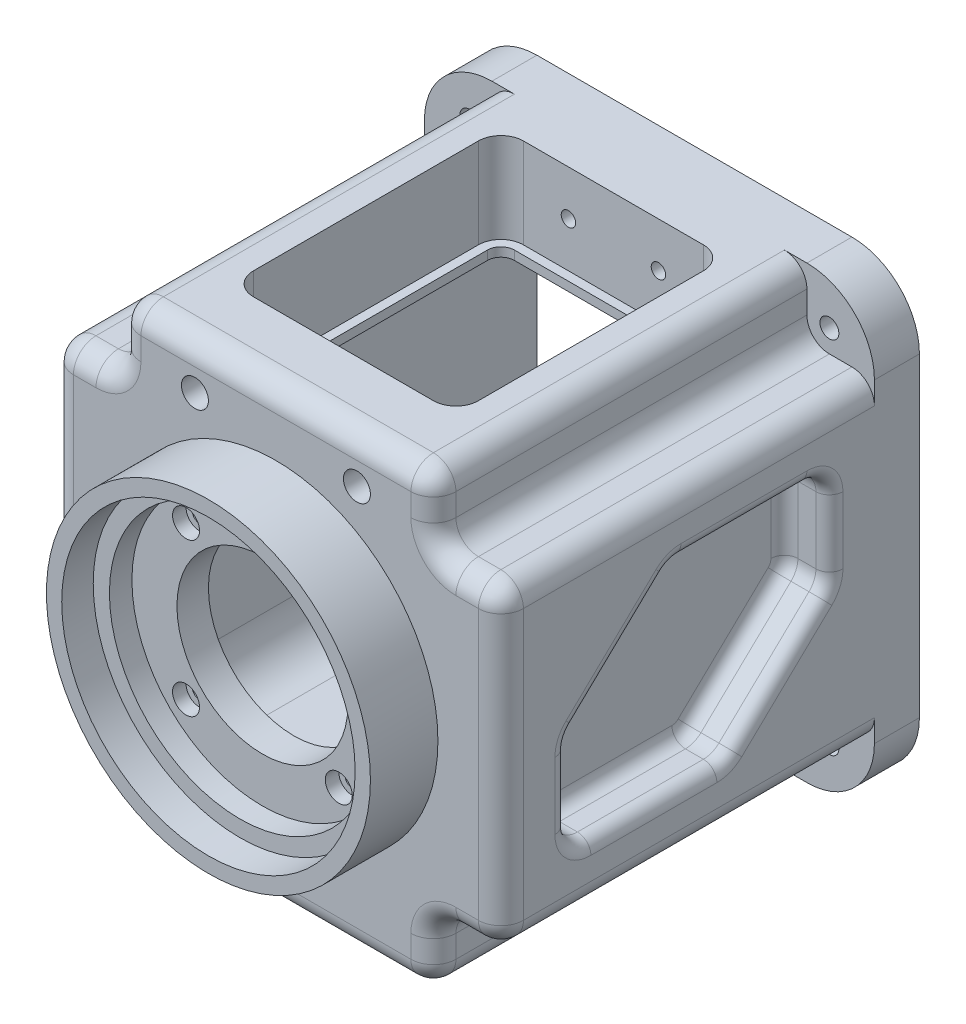
from build123d import *

# Parameters (mm, degrees)
SKETCH_1_W           = 100
SKETCH_1_H           = 100
EXTRUDE_1_DEPTH      = 93
FILLET_1_R           = 15
CUT_EXTRUDE_1_DEPTH  = 83
SKETCH_3_R           = 25
SKETCH_3_R_2         = 15
CUT_EXTRUDE_2_DEPTH  = 7
SKETCH_4_R           = 24
SKETCH_4_R_2         = 16
CUT_EXTRUDE_3_DEPTH  = 3
CHAMFER_1_SIZE       = 1
SKETCH_5_R           = 36
EXTRUDE_2_DEPTH      = 15
SKETCH_6_R           = 32.6
CUT_EXTRUDE_4_DEPTH  = 7
SKETCH_7_R           = 29
CUT_EXTRUDE_5_DEPTH  = 5
SKETCH_8_R           = 19
SKETCH_8_R_2         = 1.6
CUT_EXTRUDE_6_DEPTH  = 97
SKETCH_9_R           = 3
CUT_EXTRUDE_7_DEPTH  = 3
CUT_EXTRUDE_8_DEPTH  = 88
SKETCH_12_W          = 42.2
SKETCH_12_H          = 42.2
CUT_EXTRUDE_9_DEPTH  = 1
FILLET_3_R           = 5
CUT_EXTRUDE_10_REACH = 102
CUT_EXTRUDE_11_DEPTH = 20
CUT_EXTRUDE_12_DEPTH = 10
FILLET_4_R           = 5
FILLET_5_R           = 3
SKETCH_16_R          = 2.1
CUT_EXTRUDE_13_DEPTH = 109
CUT_EXTRUDE_14_REACH = 92
CUT_EXTRUDE_15_REACH = 110
SKETCH_18_R          = 1.6
SKETCH_19_R          = 3
CUT_EXTRUDE_16_DEPTH = 10
SKETCH_20_R          = 1.6
CUT_EXTRUDE_17_DEPTH = 31
SKETCH_21_R          = 3
CUT_EXTRUDE_18_DEPTH = 8


with BuildPart() as part:
    # 草图1 → 凸台-拉伸1 (new body)
    with BuildSketch(Plane.XY):
        Rectangle(SKETCH_1_W, SKETCH_1_H)
    extrude(amount=EXTRUDE_1_DEPTH)

    # 圆角1
    fillet_1_edges = [part.edges().sort_by_distance(p)[0] for p in [
        (50, -50, 46.5),
        (-50, -50, 46.5),
        (-50, 50, 46.5),
        (50, 50, 46.5),
    ]]
    fillet(fillet_1_edges, radius=FILLET_1_R)

    # 草图2 → 切除-拉伸1 (cut)
    with BuildSketch(Plane.XY.offset(93)):
        with BuildLine():
            Line((-35, 50), (-50, 50))
            Line((-50, 50), (-50, 35))
            Line((-50, 35), (-40, 35))
            ThreePointArc((-40, 35), (-36.464466094, 36.464466094), (-35, 40))
            Line((-35, 40), (-35, 50))
        make_face()
        with BuildLine():
            Line((50, 35), (40, 35))
            ThreePointArc((40, 35), (36.464466094, 36.464466094), (35, 40))
            Line((35, 40), (35, 50))
            Line((35, 50), (50, 50))
            Line((50, 50), (50, 35))
        make_face()
        with BuildLine():
            Line((35, -50), (35, -40))
            ThreePointArc((35, -40), (36.464466094, -36.464466094), (40, -35))
            Line((40, -35), (50, -35))
            Line((50, -35), (50, -50))
            Line((50, -50), (35, -50))
        make_face()
        with BuildLine():
            Line((-50, -35), (-40, -35))
            ThreePointArc((-40, -35), (-36.464466094, -36.464466094), (-35, -40))
            Line((-35, -40), (-35, -50))
            Line((-35, -50), (-50, -50))
            Line((-50, -50), (-50, -35))
        make_face()
    extrude(amount=-CUT_EXTRUDE_1_DEPTH, mode=Mode.SUBTRACT)

    # 草图3 → 切除-拉伸2 (cut)
    with BuildSketch(Plane.XZ.offset(50)):
        with Locations((0, 46.5)):
            Circle(SKETCH_3_R)
        with Locations((0, 46.5)):
            Circle(SKETCH_3_R_2, mode=Mode.SUBTRACT)
    extrude(amount=-CUT_EXTRUDE_2_DEPTH, mode=Mode.SUBTRACT)

    # 草图4 → 切除-拉伸3 (cut)
    with BuildSketch(Plane.XZ.offset(43)):
        with Locations((0, 46.5)):
            Circle(SKETCH_4_R)
        with Locations((0, 46.5)):
            Circle(SKETCH_4_R_2, mode=Mode.SUBTRACT)
    extrude(amount=-CUT_EXTRUDE_3_DEPTH, mode=Mode.SUBTRACT)

    # 倒角1
    chamfer_1_edges = [part.edges().sort_by_distance(p)[0] for p in [
        (-25, -50, 46.5),
        (-15, -50, 46.5),
    ]]
    chamfer(chamfer_1_edges, length=CHAMFER_1_SIZE)

    # 草图5 → 凸台-拉伸2 (add)
    with BuildSketch(Plane.XY.offset(93)):
        Circle(SKETCH_5_R)
    extrude(amount=EXTRUDE_2_DEPTH)

    # 草图6 → 切除-拉伸4 (cut)
    with BuildSketch(Plane.XY.offset(108)):
        Circle(SKETCH_6_R)
    extrude(amount=-CUT_EXTRUDE_4_DEPTH, mode=Mode.SUBTRACT)

    # 草图7 → 切除-拉伸5 (cut)
    with BuildSketch(Plane.XY.offset(101)):
        Circle(SKETCH_7_R)
    extrude(amount=-CUT_EXTRUDE_5_DEPTH, mode=Mode.SUBTRACT)

    # 草图8 → 切除-拉伸6 (cut, through all)
    with BuildSketch(Plane.XY.offset(96)):
        Circle(SKETCH_8_R)
        with Locations((-16.970562748, 16.970562748)):
            Circle(SKETCH_8_R_2)
        with Locations((16.970562748, 16.970562748)):
            Circle(SKETCH_8_R_2)
        with Locations((16.970562748, -16.970562748)):
            Circle(SKETCH_8_R_2)
        with Locations((-16.970562748, -16.970562748)):
            Circle(SKETCH_8_R_2)
    extrude(amount=-CUT_EXTRUDE_6_DEPTH, mode=Mode.SUBTRACT)

    # 草图9 → 切除-拉伸7 (cut)
    with BuildSketch(Plane.XY.offset(96)):
        with Locations((-16.970562748, 16.970562748)):
            Circle(SKETCH_9_R)
        with Locations((16.970562748, 16.970562748)):
            Circle(SKETCH_9_R)
        with Locations((-16.970562748, -16.970562748)):
            Circle(SKETCH_9_R)
        with Locations((16.970562748, -16.970562748)):
            Circle(SKETCH_9_R)
    extrude(amount=-CUT_EXTRUDE_7_DEPTH, mode=Mode.SUBTRACT)

    # 草图11 → 切除-拉伸8 (cut)
    with BuildSketch(Plane(origin=(0, 0, 0), x_dir=(-1, 0, 0), z_dir=(0, 0, -1))):
        with BuildLine():
            Line((-25, 28), (25, 28))
            ThreePointArc((25, 28), (32.071067812, 25.071067812), (35, 18))
            Line((35, 18), (35, -27))
            ThreePointArc((35, -27), (32.071067812, -34.071067812), (25, -37))
            Line((25, -37), (-25, -37))
            ThreePointArc((-25, -37), (-32.071067812, -34.071067812), (-35, -27))
            Line((-35, -27), (-35, 18))
            ThreePointArc((-35, 18), (-32.071067812, 25.071067812), (-25, 28))
        make_face()
    extrude(amount=-CUT_EXTRUDE_8_DEPTH, mode=Mode.SUBTRACT)

    # 草图12 → 切除-拉伸9 (cut)
    with BuildSketch(Plane(origin=(0, 0, 88), x_dir=(-1, 0, 0), z_dir=(0, 0, -1))):
        Rectangle(SKETCH_12_W, SKETCH_12_H)
    extrude(amount=-CUT_EXTRUDE_9_DEPTH, mode=Mode.SUBTRACT)

    # 圆角3
    fillet_3_edges = [part.edges().sort_by_distance(p)[0] for p in [
        (0, -50, 93),
        (-35, -50, 51.5),
        (-50, 0, 93),
        (-50, 35, 51.5),
        (50, 0, 93),
        (0, 50, 93),
        (50, -35, 51.5),
        (35, 50, 51.5),
        (-50, -35, 51.5),
        (-45, -35, 93),
        (-35, -45, 93),
        (-36.464466094, -36.464466094, 93),
        (35, -50, 51.5),
        (35, -45, 93),
        (45, -35, 93),
        (36.464466094, -36.464466094, 93),
        (50, 35, 51.5),
        (45, 35, 93),
        (35, 45, 93),
        (36.464466094, 36.464466094, 93),
        (-35, 50, 51.5),
        (-35, 45, 93),
        (-45, 35, 93),
        (-36.464466094, 36.464466094, 93),
    ]]
    fillet(fillet_3_edges, radius=FILLET_3_R)

    # 草图13 → 切除-拉伸10 (cut, up to next)
    with BuildSketch(Plane(origin=(0, 50, 0), x_dir=(1, 0, 0), z_dir=(0, 1, 0)), mode=Mode.PRIVATE) as cut_extrude_10_sk1:
        with BuildLine():
            Line((-20, -20), (20, -20))
            ThreePointArc((20, -20), (22.121320344, -20.878679656), (23, -23))
            Line((23, -23), (23, -73))
            ThreePointArc((23, -73), (22.121320344, -75.121320344), (20, -76))
            Line((20, -76), (-20, -76))
            ThreePointArc((-20, -76), (-22.121320344, -75.121320344), (-23, -73))
            Line((-23, -73), (-23, -23))
            ThreePointArc((-23, -23), (-22.121320344, -20.878679656), (-20, -20))
        make_face()
    cut_extrude_10_tool1 = extrude(cut_extrude_10_sk1.sketch, amount=-CUT_EXTRUDE_10_REACH, mode=Mode.PRIVATE) & part.part
    add(cut_extrude_10_tool1.solids().sort_by_distance((0, 50, 48))[0], mode=Mode.SUBTRACT)

    # 草图14 → 切除-拉伸11 (cut)
    with BuildSketch(Plane(origin=(0, 50, 0), x_dir=(1, 0, 0), z_dir=(0, 1, 0))):
        with BuildLine():
            Line((-20, -18), (20, -18))
            ThreePointArc((20, -18), (23.535533906, -19.464466094), (25, -23))
            Line((25, -23), (25, -73))
            ThreePointArc((25, -73), (23.535533906, -76.535533906), (20, -78))
            Line((20, -78), (-20, -78))
            ThreePointArc((-20, -78), (-23.535533906, -76.535533906), (-25, -73))
            Line((-25, -73), (-25, -23))
            ThreePointArc((-25, -23), (-23.535533906, -19.464466094), (-20, -18))
        make_face()
    extrude(amount=-CUT_EXTRUDE_11_DEPTH, mode=Mode.SUBTRACT)

    # 草图15 → 切除-拉伸12 (cut)
    with BuildSketch(Plane.ZY.offset(50)):
        Polygon((78, -22), (78, 0), (55, 22), (20, 22), (20, 0), (43, -22), align=None)
    cut_extrude_12 = extrude(amount=-CUT_EXTRUDE_12_DEPTH, mode=Mode.SUBTRACT)

    # 镜向1: 切除-拉伸12 across plane
    add(cut_extrude_12.mirror(Plane(origin=(0, 0, 0), x_dir=(0, 0, 1), z_dir=(1, 0, 0))), mode=Mode.SUBTRACT)

    # 圆角4
    fillet_4_edges = [part.edges().sort_by_distance(p)[0] for p in [
        (-45, -22, 78),
        (-45, -22, 43),
        (-45, 0, 20),
        (-45, 22, 20),
        (-45, 22, 55),
        (-45, 0, 78),
        (45, -22, 43),
        (45, -22, 78),
        (45, 0, 78),
        (45, 22, 55),
        (45, 22, 20),
        (45, 0, 20),
    ]]
    fillet(fillet_4_edges, radius=FILLET_4_R)

    # 圆角5
    fillet_5_edges = [part.edges().sort_by_distance(p)[0] for p in [
        (50, -9.568224014, 78),
        (40, -9.568224014, 78),
        (50, 11.044985272, 66.452969943),
        (40, 11.044985272, 66.452969943),
        (40, -22, 59.003143287),
        (40, -11.044985272, 31.547030057),
        (40, 9.568224014, 20),
        (40, 22, 38.996856713),
        (40, -20.535533906, 76.535533906),
        (40, -21.640368866, 43.144304623),
        (40, 0.171831799, 20.402143644),
        (40, 20.535533906, 21.464466094),
        (40, 21.640368866, 54.855695377),
        (40, -0.171831799, 77.597856356),
        (50, 22, 38.996856713),
        (50, 9.568224014, 20),
        (50, -11.044985272, 31.547030057),
        (50, -22, 59.003143287),
        (-50, 9.568224014, 20),
        (-40, 9.568224014, 20),
        (-50, 22, 38.996856713),
        (-40, 22, 38.996856713),
        (-40, -22, 59.003143287),
        (-40, -9.568224014, 78),
        (-40, 11.044985272, 66.452969943),
        (-40, -11.044985272, 31.547030057),
        (-40, 21.640368866, 54.855695377),
        (-40, -0.171831799, 77.597856356),
        (-40, -20.535533906, 76.535533906),
        (-40, -21.640368866, 43.144304623),
        (-40, 0.171831799, 20.402143644),
        (-40, 20.535533906, 21.464466094),
        (-50, -11.044985272, 31.547030057),
        (-50, -22, 59.003143287),
        (-50, -9.568224014, 78),
        (-50, 11.044985272, 66.452969943),
        (50, -0.171831799, 77.597856356),
        (50, 21.640368866, 54.855695377),
        (50, 20.535533906, 21.464466094),
        (50, 0.171831799, 20.402143644),
        (50, -21.640368866, 43.144304623),
        (50, -20.535533906, 76.535533906),
        (-50, 20.535533906, 21.464466094),
        (-50, 0.171831799, 20.402143644),
        (-50, -21.640368866, 43.144304623),
        (-50, -20.535533906, 76.535533906),
        (-50, -0.171831799, 77.597856356),
        (-50, 21.640368866, 54.855695377),
    ]]
    fillet(fillet_5_edges, radius=FILLET_5_R)

    # 草图16 → 切除-拉伸13 (cut, through all)
    with BuildSketch(Plane(origin=(0, 0, 0), x_dir=(-1, 0, 0), z_dir=(0, 0, -1))):
        with Locations((-40, 40)):
            Circle(SKETCH_16_R)
        with Locations((40, 40)):
            Circle(SKETCH_16_R)
        with Locations((40, -40)):
            Circle(SKETCH_16_R)
        with Locations((-40, -40)):
            Circle(SKETCH_16_R)
    extrude(amount=-CUT_EXTRUDE_13_DEPTH, mode=Mode.SUBTRACT)

    # 草图17 → 切除-拉伸14 (cut, up to next)
    with BuildSketch(Plane.XZ.offset(40), mode=Mode.PRIVATE) as cut_extrude_14_sk1:
        with BuildLine():
            Line((22.2, 52.5), (22.2, 40.5))
            ThreePointArc((22.2, 40.5), (19, 37.3), (15.8, 40.5))
            Line((15.8, 40.5), (15.8, 52.5))
            ThreePointArc((15.8, 52.5), (19, 55.7), (22.2, 52.5))
        make_face()
    cut_extrude_14_tool1 = extrude(cut_extrude_14_sk1.sketch, amount=-CUT_EXTRUDE_14_REACH, mode=Mode.PRIVATE) & part.part
    add(cut_extrude_14_tool1.solids().sort_by_distance((19, -40, 46.5))[0], mode=Mode.SUBTRACT)

    # 草图18 → 切除-拉伸15 (cut, up to next)
    with BuildSketch(Plane(origin=(0, 0, 0), x_dir=(-1, 0, 0), z_dir=(0, 0, -1)), mode=Mode.PRIVATE) as cut_extrude_15_sk1:
        with Locations((-10, 40)):
            Circle(SKETCH_18_R)
    cut_extrude_15_tool1 = extrude(cut_extrude_15_sk1.sketch, amount=-CUT_EXTRUDE_15_REACH, mode=Mode.PRIVATE) & part.part
    add(cut_extrude_15_tool1.solids().sort_by_distance((10, 40, 0))[0], mode=Mode.SUBTRACT)
    # 草图18 → 切除-拉伸15 (cut, up to next)
    with BuildSketch(Plane(origin=(0, 0, 0), x_dir=(-1, 0, 0), z_dir=(0, 0, -1)), mode=Mode.PRIVATE) as cut_extrude_15_sk2:
        with Locations((10, 40)):
            Circle(SKETCH_18_R)
    cut_extrude_15_tool2 = extrude(cut_extrude_15_sk2.sketch, amount=-CUT_EXTRUDE_15_REACH, mode=Mode.PRIVATE) & part.part
    add(cut_extrude_15_tool2.solids().sort_by_distance((-10, 40, 0))[0], mode=Mode.SUBTRACT)

    # 草图19 → 切除-拉伸16 (cut)
    with BuildSketch(Plane(origin=(0, 0, 0), x_dir=(-1, 0, 0), z_dir=(0, 0, -1))):
        with Locations((-10, 40)):
            Circle(SKETCH_19_R)
        with Locations((10, 40)):
            Circle(SKETCH_19_R)
    extrude(amount=-CUT_EXTRUDE_16_DEPTH, mode=Mode.SUBTRACT)

    # 草图20 → 切除-拉伸17 (cut, through all)
    with BuildSketch(Plane(origin=(0, 0, 78), x_dir=(-1, 0, 0), z_dir=(0, 0, -1))):
        with Locations((-18, 40)):
            Circle(SKETCH_20_R)
        with Locations((18, 40)):
            Circle(SKETCH_20_R)
    extrude(amount=-CUT_EXTRUDE_17_DEPTH, mode=Mode.SUBTRACT)

    # 草图21 → 切除-拉伸18 (cut)
    with BuildSketch(Plane.XY.offset(93)):
        with Locations((-18, 40)):
            Circle(SKETCH_21_R)
        with Locations((18, 40)):
            Circle(SKETCH_21_R)
    extrude(amount=-CUT_EXTRUDE_18_DEPTH, mode=Mode.SUBTRACT)


solid = part.part
